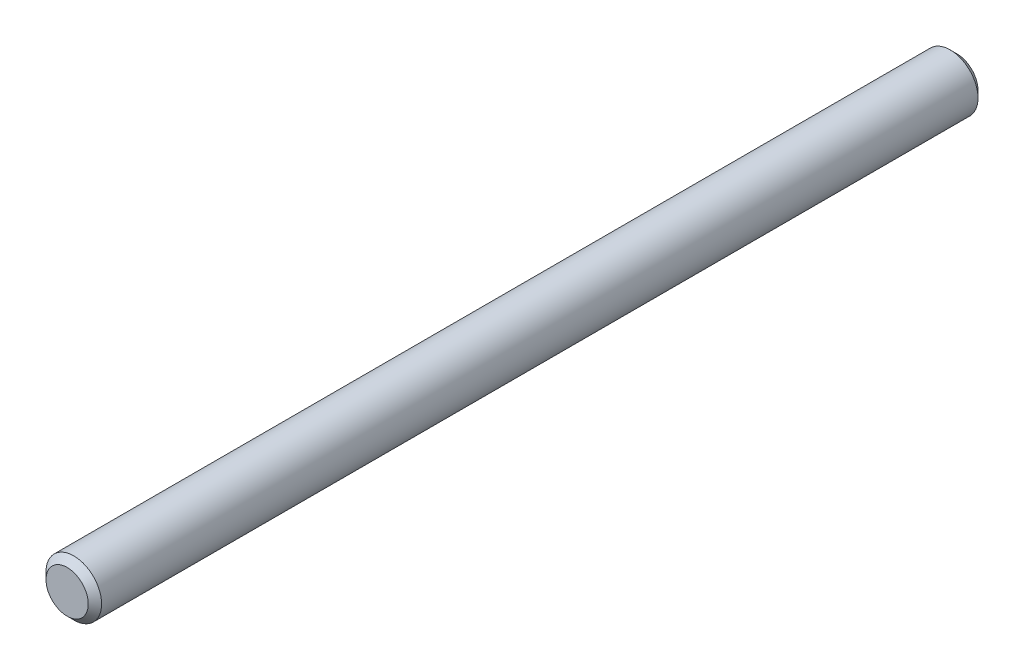
from build123d import *

# Parameters (mm, degrees)
SKETCH1_R           = 3.175
BOSS_EXTRUDE1_DEPTH = 101.6
CHAMFER1_SIZE       = 0.762


with BuildPart() as part:
    # Sketch1 → Boss-Extrude1 (new body)
    with BuildSketch(Plane.XY):
        Circle(SKETCH1_R)
    extrude(amount=BOSS_EXTRUDE1_DEPTH)

    # Chamfer1
    chamfer1_edges = [part.edges().sort_by_distance(p)[0] for p in [
        (-3.175, 0, 0),
        (-3.175, 0, 101.6),
    ]]
    chamfer(chamfer1_edges, length=CHAMFER1_SIZE)


solid = part.part
